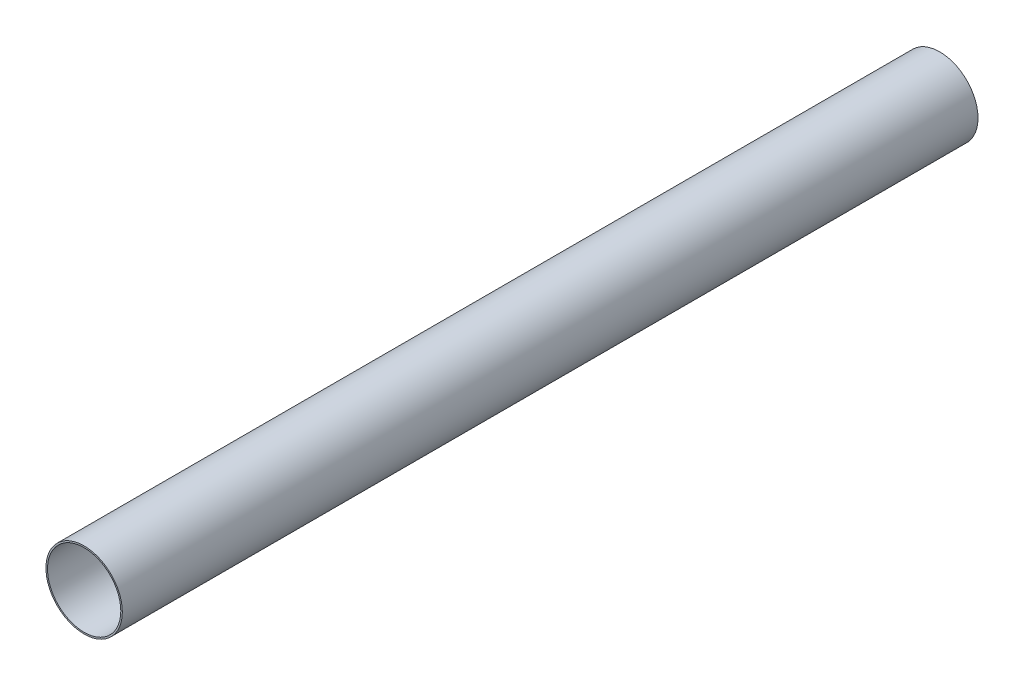
from build123d import *

# Parameters (mm, degrees)
SKETCH1_R           = 79.375
SKETCH1_R_2         = 76.2
BOSS_EXTRUDE1_DEPTH = 1778


with BuildPart() as part:
    # Sketch1 → Boss-Extrude1 (new body)
    with BuildSketch(Plane.XY):
        Circle(SKETCH1_R)
        Circle(SKETCH1_R_2, mode=Mode.SUBTRACT)
    extrude(amount=BOSS_EXTRUDE1_DEPTH)


solid = part.part
